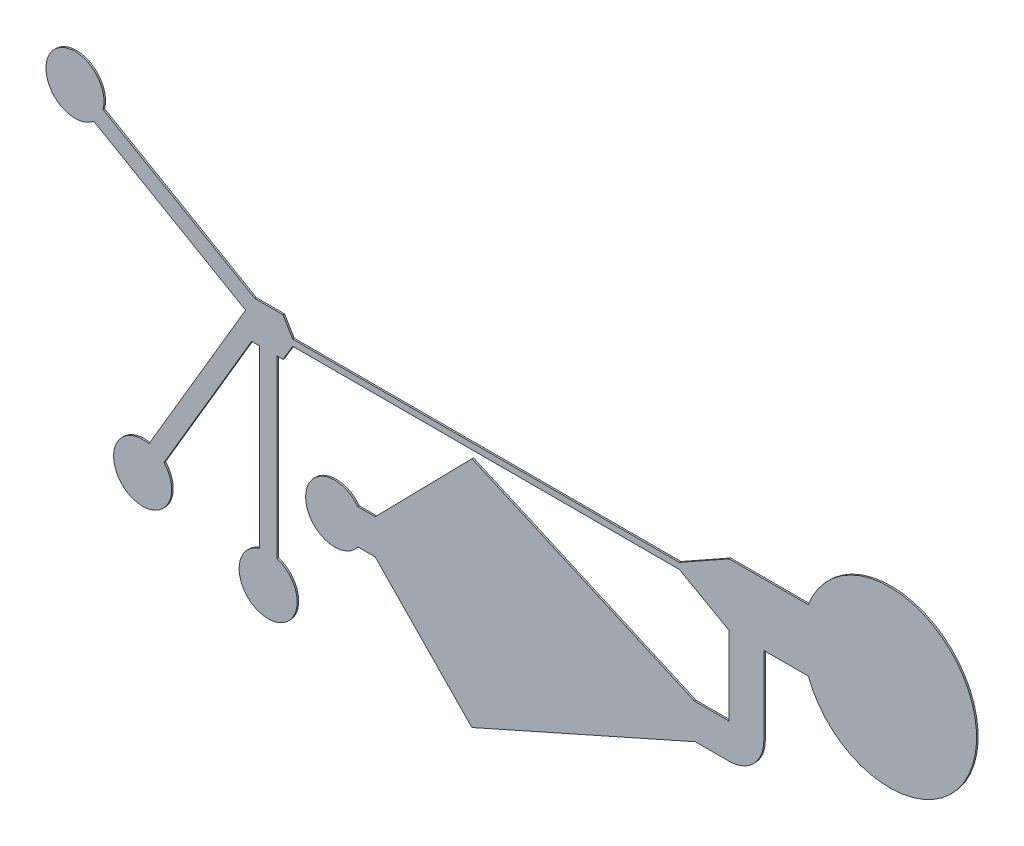
from build123d import *

# Parameters (mm, degrees)
BOSS_EXTRUDE1_DEPTH = 0.04


with BuildPart() as part:
    # Sketch1 → Boss-Extrude1 (new body)
    with BuildSketch(Plane.XY):
        with BuildLine():
            Line((-1.32802474, 0.67738204), (-1.07802474, 0.25738204))
            Line((-1.07802474, 0.25738204), (8.92197526, 0.25738204))
            Line((8.92197526, 0.25738204), (10.20197526, 0.97738204))
            Line((10.20197526, 0.97738204), (10.514497177, 0.97738204))
            Line((10.514497177, 0.97738204), (10.93536953, 0.97738204))
            Line((10.93536953, 0.97738204), (12.25197526, 0.97738204))
            ThreePointArc((12.25197526, 0.97738204), (16.604949345, 0.17738204), (12.25197526, -0.62261796))
            Line((12.25197526, -0.62261796), (11.10197526, -0.62261796))
            Line((11.10197526, -0.62261796), (11.10197526, -1.42261796))
            Line((11.10197526, -1.42261796), (11.10197526, -1.527549767))
            Line((11.10197526, -1.527549767), (11.10197526, -2.327549767))
            Line((11.10197526, -2.327549767), (11.10197526, -2.653523035))
            ThreePointArc((11.10197526, -2.653523035), (10.838371363, -3.289919138), (10.20197526, -3.553523035))
            Line((10.20197526, -3.553523035), (9.33171427, -3.553523035))
            Line((9.33171427, -3.553523035), (3.555572379, -6.12261796))
            Line((3.555572379, -6.12261796), (1.054032996, -3.553523035))
            Line((1.054032996, -3.553523035), (0.608362539, -3.553523035))
            ThreePointArc((0.608362539, -3.553523035), (-0.743782707, -3.110017255), (0.604032996, -2.653523035))
            Line((0.604032996, -2.653523035), (1.054032996, -2.653523035))
            Line((1.054032996, -2.653523035), (3.555572379, -0.10261796))
            Line((3.555572379, -0.10261796), (9.311250991, -2.653523035))
            Line((9.311250991, -2.653523035), (10.20197526, -2.653523035))
            Line((10.20197526, -2.653523035), (10.20197526, -2.327549767))
            Line((10.20197526, -2.327549767), (10.20197526, -1.52261796))
            Line((10.20197526, -1.52261796), (10.20197526, -1.42261796))
            Line((10.20197526, -1.42261796), (10.20197526, -0.62261796))
            Line((10.20197526, -0.62261796), (8.92197526, 0.09738204))
            Line((8.92197526, 0.09738204), (-1.07802474, 0.09738204))
            Line((-1.07802474, 0.09738204), (-1.32802474, -0.32261796))
            Line((-1.32802474, -0.32261796), (-1.48802474, -0.32261796))
            Line((-1.48802474, -0.32261796), (-1.48802474, -4.82261796))
            Line((-1.48802474, -4.82261796), (-1.48802474, -4.857163559))
            ThreePointArc((-1.48802474, -4.857163559), (-1.71302474, -6.32261796), (-1.93802474, -4.857163559))
            Line((-1.93802474, -4.857163559), (-1.93802474, -4.82261796))
            Line((-1.93802474, -4.82261796), (-1.93802474, -0.32261796))
            Line((-1.93802474, -0.32261796), (-2.13802474, -0.32261796))
            Line((-2.13802474, -0.32261796), (-4.375941954, -4.119846244))
            Line((-4.375941954, -4.119846244), (-4.405297747, -4.16965624))
            ThreePointArc((-4.405297747, -4.16965624), (-5.332880663, -5.32627698), (-4.795009179, -3.94465624))
            Line((-4.795009179, -3.94465624), (-4.763622434, -3.891364637))
            Line((-4.763622434, -3.891364637), (-2.295650959, 0.296212559))
            Line((-2.295650959, 0.296212559), (-6.192765276, 2.546212559))
            Line((-6.192765276, 2.546212559), (-6.224617122, 2.562462753))
            ThreePointArc((-6.224617122, 2.562462753), (-7.341518741, 3.537122923), (-5.982350992, 2.945434913))
            Line((-5.982350992, 2.945434913), (-5.952970183, 2.92738204))
            Line((-5.952970183, 2.92738204), (-2.421945704, 0.888744107))
            Line((-2.421945704, 0.888744107), (-2.055855866, 0.67738204))
            Line((-2.055855866, 0.67738204), (-1.625502745, 0.67738204))
            Line((-1.625502745, 0.67738204), (-1.32802474, 0.67738204))
        make_face()
    extrude(amount=BOSS_EXTRUDE1_DEPTH)


solid = part.part
